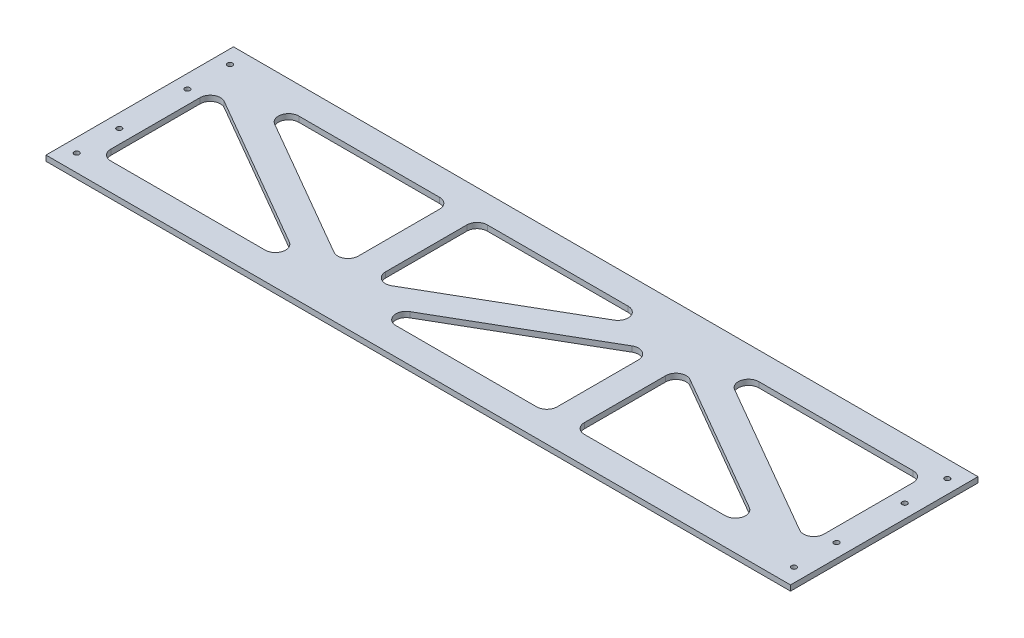
from build123d import *

# Parameters (mm, degrees)
SKETCH1_W           = 1386.9289
SKETCH1_H           = 349.25
SKETCH1_W_2         = 1285.3289
SKETCH1_H_2         = 247.65
BOSS_EXTRUDE1_DEPTH = 10.16
FILLET1_R           = 19.05
SKETCH4_R           = 4.7625
CUT_EXTRUDE1_DEPTH  = 11.16


with BuildPart() as part:
    # Sketch1 → Boss-Extrude1 (new body)
    with BuildSketch(Plane(origin=(0, 0, 0), x_dir=(1, 0, 0), z_dir=(0, 1, 0))):
        with Locations((693.46445, 174.625)):
            Rectangle(SKETCH1_W, SKETCH1_H)
        with Locations((693.46445, 174.625)):
            Rectangle(SKETCH1_W_2, SKETCH1_H_2, mode=Mode.SUBTRACT)
        Polygon((453.842966667, 65.481790785), (50.8, 298.45), (50.8, 269.112055616), (428.487319876, 50.8), (453.842966667, 50.8), align=None)
        Polygon((101.55564679, 298.45), (50.8, 298.45), (453.842966667, 65.481790785), (453.842966667, 94.819735169), align=None)
        Polygon((453.842966667, 94.819735169), (453.842966667, 65.481790785), (453.842966667, 50.8), (479.242966667, 50.8), (479.242966667, 298.45), (453.842966667, 298.45), align=None)
        Polygon((504.642966667, 298.45), (479.242966667, 298.45), (479.242966667, 50.8), (504.642966667, 50.8), (504.642966667, 65.481790785), (504.642966667, 94.819735169), align=None)
        Polygon((882.285933333, 298.45), (856.930286543, 298.45), (504.642966667, 94.819735169), (504.642966667, 65.481790785), (882.285933333, 283.768209215), align=None)
        Polygon((504.642966667, 65.481790785), (504.642966667, 50.8), (529.998613457, 50.8), (882.285933333, 254.430264831), (882.285933333, 283.768209215), align=None)
        Polygon((907.685933333, 298.45), (882.285933333, 298.45), (882.285933333, 283.768209215), (882.285933333, 254.430264831), (882.285933333, 50.8), (907.685933333, 50.8), align=None)
        Polygon((933.085933333, 298.45), (907.685933333, 298.45), (907.685933333, 50.8), (933.085933333, 50.8), (933.085933333, 254.430264831), (933.085933333, 283.768209215), align=None)
        Polygon((1336.1289, 50.8), (933.085933333, 283.768209215), (933.085933333, 254.430264831), (1285.37325321, 50.8), align=None)
        Polygon((958.441580124, 298.45), (933.085933333, 298.45), (933.085933333, 283.768209215), (1336.1289, 50.8), (1336.1289, 80.137944384), align=None)
    extrude(amount=BOSS_EXTRUDE1_DEPTH)

    # Fillet1
    fillet1_edges = [part.edges().sort_by_distance(p)[0] for p in [
        (428.487319876, 5.08, -50.8),
        (50.8, 5.08, -269.112055616),
        (50.8, 5.08, -50.8),
        (1336.1289, 5.08, -80.137944384),
        (1336.1289, 5.08, -298.45),
        (958.441580124, 5.08, -298.45),
        (856.930286543, 5.08, -298.45),
        (504.642966667, 5.08, -298.45),
        (504.642966667, 5.08, -94.819735169),
        (453.842966667, 5.08, -298.45),
        (101.55564679, 5.08, -298.45),
        (453.842966667, 5.08, -94.819735169),
        (529.998613457, 5.08, -50.8),
        (882.285933333, 5.08, -50.8),
        (882.285933333, 5.08, -254.430264831),
        (933.085933333, 5.08, -50.8),
        (1285.37325321, 5.08, -50.8),
        (933.085933333, 5.08, -254.430264831),
    ]]
    fillet(fillet1_edges, radius=FILLET1_R)

    # Sketch4 → Cut-Extrude1 (cut, through all)
    with BuildSketch(Plane(origin=(0, 10.16, 0), x_dir=(1, 0, 0), z_dir=(0, 1, 0))):
        with Locations((25.4, 317.5)):
            Circle(SKETCH4_R)
        with Locations((25.4, 238.125)):
            Circle(SKETCH4_R)
        with Locations((25.4, 111.125)):
            Circle(SKETCH4_R)
        with Locations((25.4, 31.75)):
            Circle(SKETCH4_R)
        with Locations((1361.5289, 31.75)):
            Circle(SKETCH4_R)
        with Locations((1361.5289, 111.125)):
            Circle(SKETCH4_R)
        with Locations((1361.5289, 238.125)):
            Circle(SKETCH4_R)
        with Locations((1361.5289, 317.5)):
            Circle(SKETCH4_R)
    extrude(amount=-CUT_EXTRUDE1_DEPTH, mode=Mode.SUBTRACT)


solid = part.part
